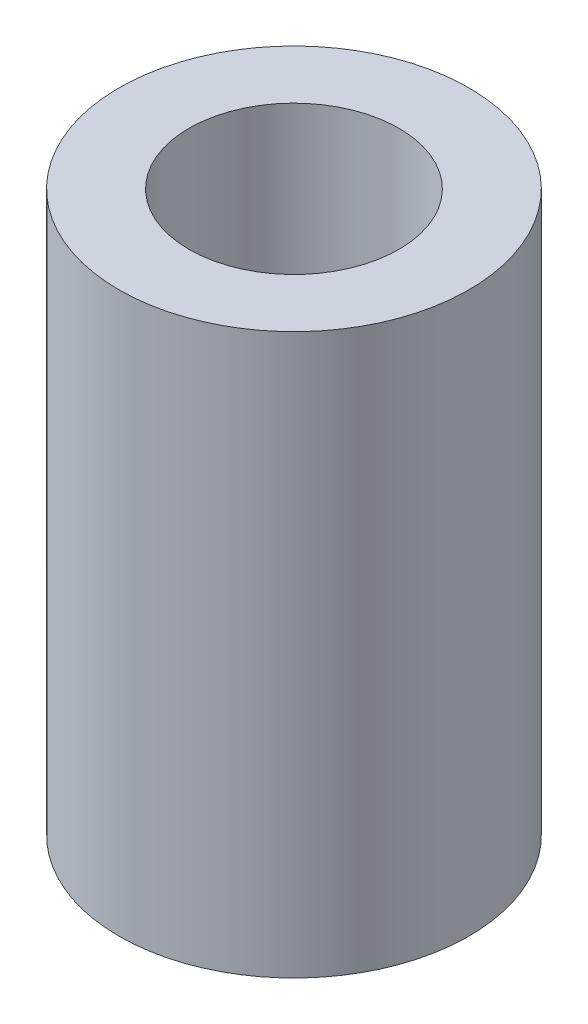
from build123d import *

# Parameters (mm, degrees)
SKETCH1_R           = 2.5
SKETCH1_R_2         = 1.5
BOSS_EXTRUDE1_DEPTH = 8


with BuildPart() as part:
    # Sketch1 → Boss-Extrude1 (new body)
    with BuildSketch(Plane(origin=(0, 0, 0), x_dir=(1, 0, 0), z_dir=(0, 1, 0))):
        with Locations((-0.488949405, 0.114567218)):
            Circle(SKETCH1_R)
        with Locations((-0.488949405, 0.114567218)):
            Circle(SKETCH1_R_2, mode=Mode.SUBTRACT)
    extrude(amount=-BOSS_EXTRUDE1_DEPTH)


solid = part.part
